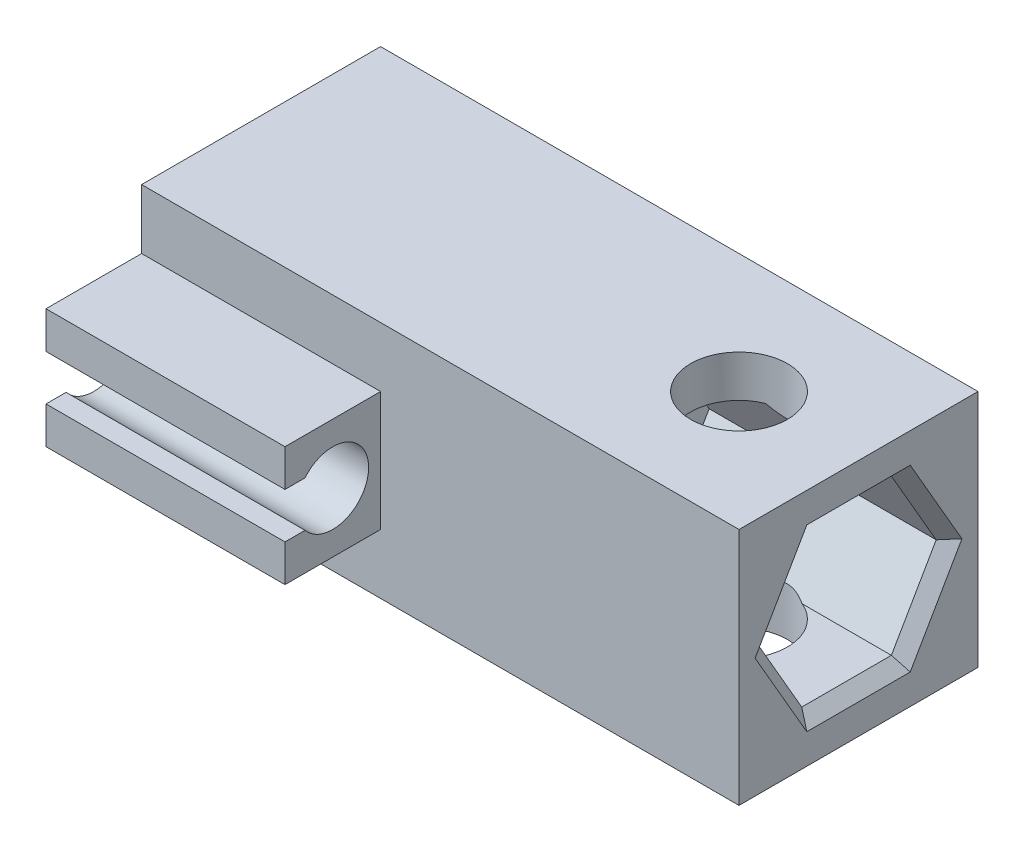
from build123d import *

# Parameters (mm, degrees)
SKETCH1_W           = 50
SKETCH1_H           = 20
SKETCH1_R           = 4.05
BOSS_EXTRUDE1_DEPTH = 20
SKETCH2_R           = 4.1
CUT_EXTRUDE1_DEPTH  = 51
CUT_EXTRUDE2_DEPTH  = 20
BOSS_EXTRUDE3_DEPTH = 20
CHAMFER1_SIZE       = 1


with BuildPart() as part:
    # Sketch1 → Boss-Extrude1 (new body)
    with BuildSketch(Plane(origin=(0, 0, 0), x_dir=(1, 0, 0), z_dir=(0, 1, 0))):
        Rectangle(SKETCH1_W, SKETCH1_H)
        with Locations((15, 0)):
            Circle(SKETCH1_R, mode=Mode.SUBTRACT)
    extrude(amount=BOSS_EXTRUDE1_DEPTH)

    # Sketch2 → Cut-Extrude1 (cut, through all)
    with BuildSketch(Plane.ZY.offset(25)):
        with Locations((0, 10)):
            Circle(SKETCH2_R)
    extrude(amount=-CUT_EXTRUDE1_DEPTH, mode=Mode.SUBTRACT)

    # Sketch3 → Cut-Extrude2 (cut)
    with BuildSketch(Plane(origin=(25, 0, 0), x_dir=(0, 0, -1), z_dir=(1, 0, 0))):
        Polygon((-3.75, 16.495190528), (-7.5, 10), (-3.75, 3.504809472), (3.75, 3.504809472), (7.5, 10), (3.75, 16.495190528), align=None)
    extrude(amount=-CUT_EXTRUDE2_DEPTH, mode=Mode.SUBTRACT)

    # Sketch8 → Boss-Extrude3 (add)
    with BuildSketch(Plane.ZY.offset(25)):
        with BuildLine():
            Line((18, 15), (18, 11.9))
            Line((18, 11.9), (16.321637353, 11.9))
            ThreePointArc((16.321637353, 11.9), (11, 10), (16.321637353, 8.1))
            Line((16.321637353, 8.1), (18, 8.1))
            Line((18, 8.1), (18, 5))
            Line((18, 5), (10, 5))
            Line((10, 5), (10, 15))
            Line((10, 15), (18, 15))
        make_face()
    extrude(amount=-BOSS_EXTRUDE3_DEPTH)

    # Chamfer1
    chamfer1_edges = [part.edges().sort_by_distance(p)[0] for p in [
        (25, 16.495190528, 0),
        (25, 13.247595264, 5.625),
        (25, 6.752404736, 5.625),
        (25, 3.504809472, 0),
        (25, 6.752404736, -5.625),
        (25, 13.247595264, -5.625),
    ]]
    chamfer(chamfer1_edges, length=CHAMFER1_SIZE)


solid = part.part
